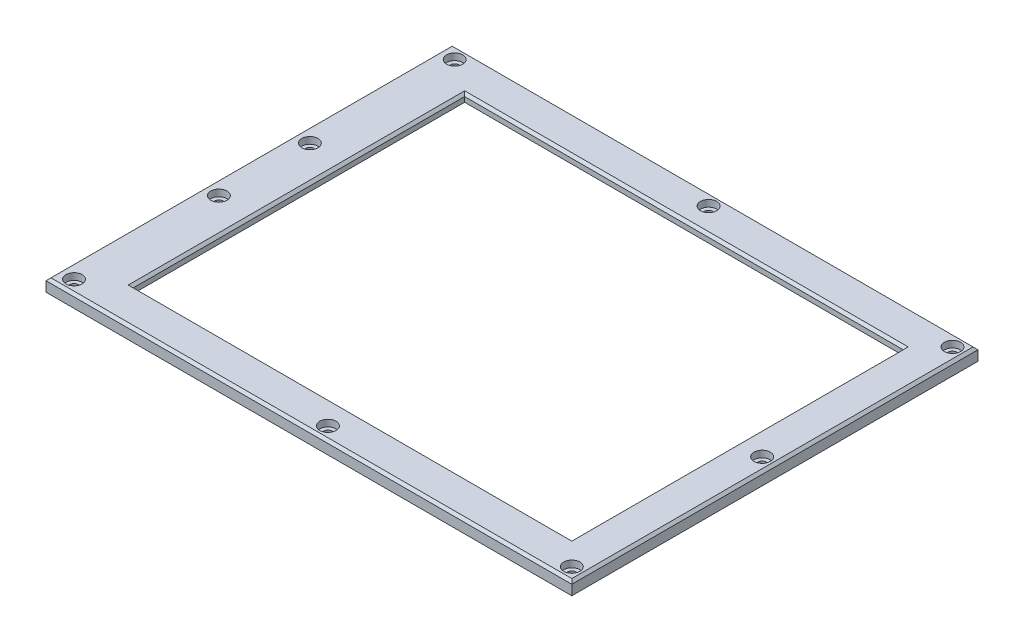
from build123d import *

# Parameters (mm, degrees)
SKETCH1_W                      = 211
SKETCH1_H                      = 163
SKETCH1_W_2                    = 176
SKETCH1_H_2                    = 133
BOSS_EXTRUDE1_DEPTH            = 5
CUT_EXTRUDE1_START             = -5
CUT_EXTRUDE1_DEPTH             = 2
CBORE_FOR_M3_SHCS1_D           = 3.4
CBORE_FOR_M3_SHCS1_DEPTH       = 5
CBORE_FOR_M3_SHCS1_CBORE_D     = 6.5
CBORE_FOR_M3_SHCS1_CBORE_DEPTH = 2.68
CHAMFER2_SIZE                  = 1


with BuildPart() as part:
    # Sketch1 → Boss-Extrude1 (new body)
    with BuildSketch(Plane(origin=(0, 0, 0), x_dir=(1, 0, 0), z_dir=(0, 1, 0))):
        with Locations((-2.5, 0)):
            Rectangle(SKETCH1_W, SKETCH1_H)
        Rectangle(SKETCH1_W_2, SKETCH1_H_2, mode=Mode.SUBTRACT)
    extrude(amount=BOSS_EXTRUDE1_DEPTH)

    # Sketch2 → Cut-Extrude1 (cut)
    with BuildSketch(Plane(origin=(0, 5, 0), x_dir=(1, 0, 0), z_dir=(0, 1, 0)).offset(CUT_EXTRUDE1_START)):
        Polygon((-95.75, -71.25), (92.75, -71.25), (92.75, 71.25), (-95.75, 71.25), (-95.75, 10.25), (-102.25, 10.25), (-102.25, 6.75), (-108, 6.75), (-108, -6.75), (-102.25, -6.75), (-102.25, -10.25), (-95.75, -10.25), align=None)
    extrude(amount=CUT_EXTRUDE1_DEPTH, mode=Mode.SUBTRACT)

    # CBORE for M3 SHCS1
    with Locations(Plane(origin=(0, 5, 0), x_dir=(1, 0, 0), z_dir=(0, 1, 0))):
        with Locations((-101.875, 76.375), (0, 76.375), (97.875, 76.375), (97.875, -76.375), (97.875, 0), (0, -76.375), (-101.875, -76.375), (-101.875, -18.25), (-101.875, 18.25)):
            CounterBoreHole(CBORE_FOR_M3_SHCS1_D / 2, CBORE_FOR_M3_SHCS1_CBORE_D / 2, CBORE_FOR_M3_SHCS1_CBORE_DEPTH, depth=CBORE_FOR_M3_SHCS1_DEPTH)

    # Chamfer2
    chamfer2_edges = [part.edges().sort_by_distance(p)[0] for p in [
        (-2.5, 5, 81.5),
        (0, 5, -66.5),
        (-88, 5, 0),
        (0, 5, 66.5),
        (-108, 5, 0),
        (88, 5, 0),
        (-2.5, 5, -81.5),
        (103, 5, 0),
    ]]
    chamfer(chamfer2_edges, length=CHAMFER2_SIZE)


solid = part.part
